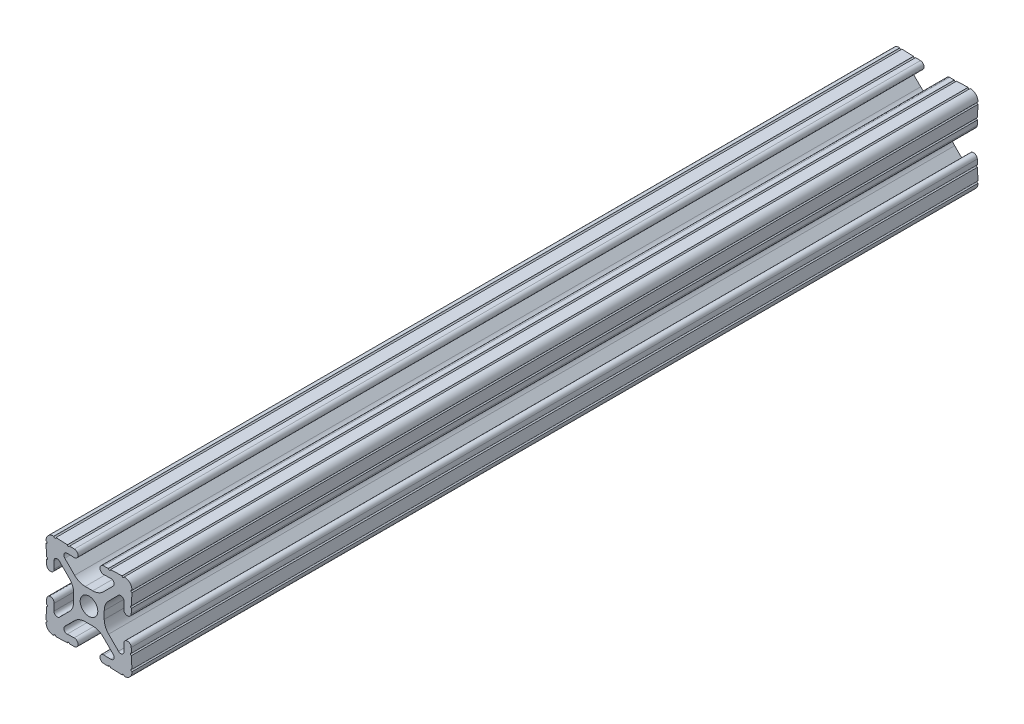
from build123d import *

# Parameters (mm, degrees)
SKETCH3_R      = 2.6035
EXTRUDE1_DEPTH = 125


with BuildPart() as part:
    # Sketch3 → Extrude1 (new body, symmetric)
    with BuildSketch(Plane.XY):
        with BuildLine():
            Line((-1.115277175, 4.5085), (1.115277175, 4.5085))
            ThreePointArc((1.115277175, 4.5085), (2.806584872, 4.844922018), (4.240406305, 5.80297087))
            Line((4.240406305, 5.80297087), (7.148423664, 8.710988229))
            ThreePointArc((7.148423664, 8.710988229), (7.349906316, 9.772227925), (6.436353897, 10.348636575))
            Line((6.436353897, 10.348636575), (4.381960454, 10.276895575))
            ThreePointArc((4.381960454, 10.276895575), (3.239173075, 11.342562046), (4.304839546, 12.485349424))
            Line((4.304839546, 12.485349424), (5.728246175, 12.535055879))
            ThreePointArc((5.728246175, 12.535055879), (6.054756855, 12.230579745), (6.35923299, 12.557090424))
            Line((6.35923299, 12.557090424), (9.782092278, 12.676619304))
            ThreePointArc((9.782092278, 12.676619304), (10.108602958, 12.37214317), (10.413079092, 12.69865385))
            ThreePointArc((10.413079092, 12.69865385), (12.052764565, 12.052764565), (12.69865385, 10.413079092))
            ThreePointArc((12.69865385, 10.413079092), (12.37214317, 10.108602958), (12.676619304, 9.782092278))
            Line((12.676619304, 9.782092278), (12.557090424, 6.35923299))
            ThreePointArc((12.557090424, 6.35923299), (12.230579745, 6.054756855), (12.535055879, 5.728246175))
            Line((12.535055879, 5.728246175), (12.485349424, 4.304839546))
            ThreePointArc((12.485349424, 4.304839546), (11.342562046, 3.239173075), (10.276895575, 4.381960454))
            Line((10.276895575, 4.381960454), (10.348636575, 6.436353897))
            ThreePointArc((10.348636575, 6.436353897), (9.772227925, 7.349906316), (8.710988229, 7.148423664))
            Line((8.710988229, 7.148423664), (5.80297087, 4.240406305))
            ThreePointArc((5.80297087, 4.240406305), (4.844922018, 2.806584872), (4.5085, 1.115277175))
            Line((4.5085, 1.115277175), (4.5085, -1.115277175))
            ThreePointArc((4.5085, -1.115277175), (4.844922018, -2.806584872), (5.80297087, -4.240406305))
            Line((5.80297087, -4.240406305), (8.710988229, -7.148423664))
            ThreePointArc((8.710988229, -7.148423664), (9.772227925, -7.349906316), (10.348636575, -6.436353897))
            Line((10.348636575, -6.436353897), (10.276895575, -4.381960454))
            ThreePointArc((10.276895575, -4.381960454), (11.342562046, -3.239173075), (12.485349424, -4.304839546))
            Line((12.485349424, -4.304839546), (12.535055879, -5.728246175))
            ThreePointArc((12.535055879, -5.728246175), (12.230579745, -6.054756855), (12.557090424, -6.35923299))
            Line((12.557090424, -6.35923299), (12.676619304, -9.782092278))
            ThreePointArc((12.676619304, -9.782092278), (12.37214317, -10.108602958), (12.69865385, -10.413079092))
            ThreePointArc((12.69865385, -10.413079092), (12.052764565, -12.052764565), (10.413079092, -12.69865385))
            ThreePointArc((10.413079092, -12.69865385), (10.108602958, -12.37214317), (9.782092278, -12.676619304))
            Line((9.782092278, -12.676619304), (6.35923299, -12.557090424))
            ThreePointArc((6.35923299, -12.557090424), (6.054756855, -12.230579745), (5.728246175, -12.535055879))
            Line((5.728246175, -12.535055879), (4.304839546, -12.485349424))
            ThreePointArc((4.304839546, -12.485349424), (3.239173075, -11.342562046), (4.381960454, -10.276895575))
            Line((4.381960454, -10.276895575), (6.436353897, -10.348636575))
            ThreePointArc((6.436353897, -10.348636575), (7.349906316, -9.772227925), (7.148423664, -8.710988229))
            Line((7.148423664, -8.710988229), (4.240406305, -5.80297087))
            ThreePointArc((4.240406305, -5.80297087), (2.806584872, -4.844922018), (1.115277175, -4.5085))
            Line((1.115277175, -4.5085), (-1.115277175, -4.5085))
            ThreePointArc((-1.115277175, -4.5085), (-2.806584872, -4.844922018), (-4.240406305, -5.80297087))
            Line((-4.240406305, -5.80297087), (-7.148423664, -8.710988229))
            ThreePointArc((-7.148423664, -8.710988229), (-7.349906316, -9.772227925), (-6.436353897, -10.348636575))
            Line((-6.436353897, -10.348636575), (-4.381960454, -10.276895575))
            ThreePointArc((-4.381960454, -10.276895575), (-3.239173075, -11.342562046), (-4.304839546, -12.485349424))
            Line((-4.304839546, -12.485349424), (-5.728246175, -12.535055879))
            ThreePointArc((-5.728246175, -12.535055879), (-6.054756855, -12.230579745), (-6.35923299, -12.557090424))
            Line((-6.35923299, -12.557090424), (-9.782092278, -12.676619304))
            ThreePointArc((-9.782092278, -12.676619304), (-10.108602958, -12.37214317), (-10.413079092, -12.69865385))
            ThreePointArc((-10.413079092, -12.69865385), (-12.052764565, -12.052764565), (-12.69865385, -10.413079092))
            ThreePointArc((-12.69865385, -10.413079092), (-12.37214317, -10.108602958), (-12.676619304, -9.782092278))
            Line((-12.676619304, -9.782092278), (-12.557090424, -6.35923299))
            ThreePointArc((-12.557090424, -6.35923299), (-12.230579745, -6.054756855), (-12.535055879, -5.728246175))
            Line((-12.535055879, -5.728246175), (-12.485349424, -4.304839546))
            ThreePointArc((-12.485349424, -4.304839546), (-11.342562046, -3.239173075), (-10.276895575, -4.381960454))
            Line((-10.276895575, -4.381960454), (-10.348636575, -6.436353897))
            ThreePointArc((-10.348636575, -6.436353897), (-9.772227925, -7.349906316), (-8.710988229, -7.148423664))
            Line((-8.710988229, -7.148423664), (-5.80297087, -4.240406305))
            ThreePointArc((-5.80297087, -4.240406305), (-4.844922018, -2.806584872), (-4.5085, -1.115277175))
            Line((-4.5085, -1.115277175), (-4.5085, 1.115277175))
            ThreePointArc((-4.5085, 1.115277175), (-4.844922018, 2.806584872), (-5.80297087, 4.240406305))
            Line((-5.80297087, 4.240406305), (-8.710988229, 7.148423664))
            ThreePointArc((-8.710988229, 7.148423664), (-9.772227925, 7.349906316), (-10.348636575, 6.436353897))
            Line((-10.348636575, 6.436353897), (-10.276895575, 4.381960454))
            ThreePointArc((-10.276895575, 4.381960454), (-11.342562046, 3.239173075), (-12.485349424, 4.304839546))
            Line((-12.485349424, 4.304839546), (-12.535055879, 5.728246175))
            ThreePointArc((-12.535055879, 5.728246175), (-12.230579745, 6.054756855), (-12.557090424, 6.35923299))
            Line((-12.557090424, 6.35923299), (-12.676619304, 9.782092278))
            ThreePointArc((-12.676619304, 9.782092278), (-12.37214317, 10.108602958), (-12.69865385, 10.413079092))
            ThreePointArc((-12.69865385, 10.413079092), (-12.052764565, 12.052764565), (-10.413079092, 12.69865385))
            ThreePointArc((-10.413079092, 12.69865385), (-10.108602958, 12.37214317), (-9.782092278, 12.676619304))
            Line((-9.782092278, 12.676619304), (-6.35923299, 12.557090424))
            ThreePointArc((-6.35923299, 12.557090424), (-6.054756855, 12.230579745), (-5.728246175, 12.535055879))
            Line((-5.728246175, 12.535055879), (-4.304839546, 12.485349424))
            ThreePointArc((-4.304839546, 12.485349424), (-3.239173075, 11.342562046), (-4.381960454, 10.276895575))
            Line((-4.381960454, 10.276895575), (-6.436353897, 10.348636575))
            ThreePointArc((-6.436353897, 10.348636575), (-7.349906316, 9.772227925), (-7.148423664, 8.710988229))
            Line((-7.148423664, 8.710988229), (-4.240406305, 5.80297087))
            ThreePointArc((-4.240406305, 5.80297087), (-2.806584872, 4.844922018), (-1.115277175, 4.5085))
        make_face()
        Circle(SKETCH3_R, mode=Mode.SUBTRACT)
    extrude(amount=EXTRUDE1_DEPTH, both=True)


solid = part.part
